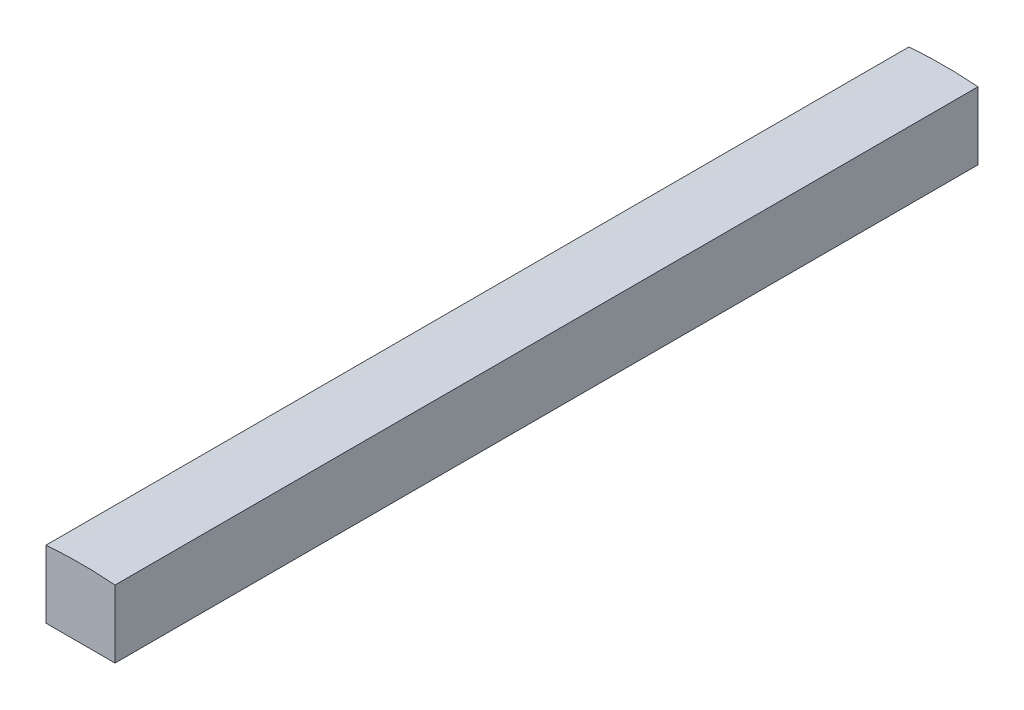
from build123d import *

# Parameters (mm, degrees)
AUFSATZ_LINEAR_AUSTRAGEN1_DEPTH = 500


with BuildPart() as part:
    # Skizze1 → Aufsatz-Linear austragen1 (new body)
    with BuildSketch(Plane.XY):
        with BuildLine():
            Line((-20, 206), (-20, 245.185643952))
            ThreePointArc((-20, 245.185643952), (0, 246), (20, 245.185643952))
            Line((20, 245.185643952), (20, 206))
            Line((20, 206), (-20, 206))
        make_face()
    extrude(amount=AUFSATZ_LINEAR_AUSTRAGEN1_DEPTH)


solid = part.part
